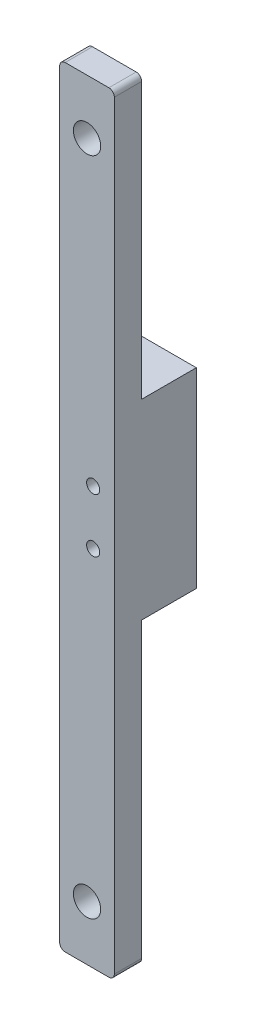
from build123d import *

# Parameters (mm, degrees)
SKETCH1_W           = 10
SKETCH1_H           = 141
SKETCH1_R           = 2.5
BOSS_EXTRUDE1_DEPTH = 5
SKETCH3_W           = 10
SKETCH3_H           = 35
BOSS_EXTRUDE3_DEPTH = 10
SKETCH4_R           = 1.2
CUT_EXTRUDE1_DEPTH  = 15
FILLET1_R           = 1


with BuildPart() as part:
    # Sketch1 → Boss-Extrude1 (new body)
    with BuildSketch(Plane.XY):
        with Locations((5, 70.5)):
            Rectangle(SKETCH1_W, SKETCH1_H)
        with Locations((5, 131)):
            Circle(SKETCH1_R, mode=Mode.SUBTRACT)
        with Locations((5, 10)):
            Circle(SKETCH1_R, mode=Mode.SUBTRACT)
    extrude(amount=BOSS_EXTRUDE1_DEPTH)

    # Sketch3 → Boss-Extrude3 (add)
    with BuildSketch(Plane(origin=(0, 0, 0), x_dir=(-1, 0, 0), z_dir=(0, 0, -1))):
        with Locations((-5, 72.121118493)):
            Rectangle(SKETCH3_W, SKETCH3_H)
    extrude(amount=BOSS_EXTRUDE3_DEPTH)

    # Sketch4 → Cut-Extrude1 (cut)
    with BuildSketch(Plane(origin=(0, 0, -10), x_dir=(-1, 0, 0), z_dir=(0, 0, -1))):
        with Locations((-6.118193933, 66.494048402)):
            Circle(SKETCH4_R)
        with Locations((-6.118193933, 76.394048402)):
            Circle(SKETCH4_R)
    extrude(amount=-CUT_EXTRUDE1_DEPTH, mode=Mode.SUBTRACT)

    # Fillet1
    fillet1_edges = [part.edges().sort_by_distance(p)[0] for p in [
        (0, 141, 2.5),
        (10, 141, 2.5),
        (10, 0, 2.5),
        (0, 0, 2.5),
    ]]
    fillet(fillet1_edges, radius=FILLET1_R)


solid = part.part
